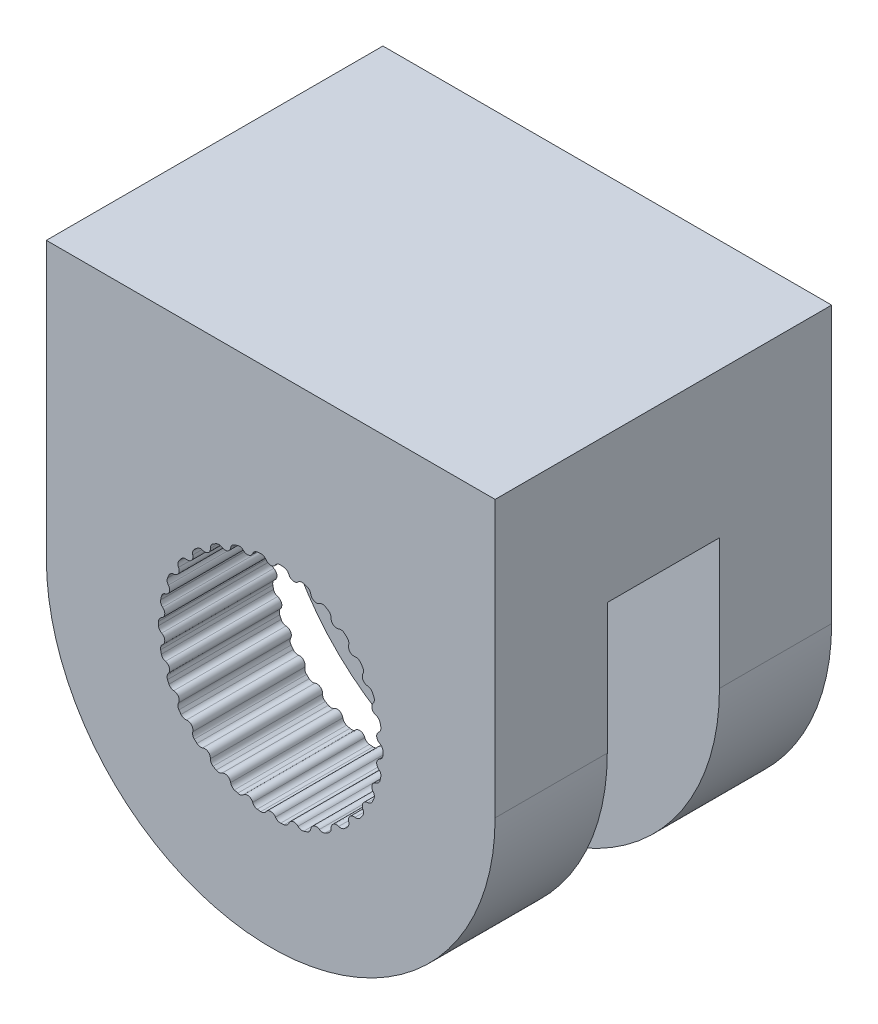
from build123d import *

# Parameters (mm, degrees)
BOSS_EXTRUDE1_DEPTH     = 10
BOSS_EXTRUDE2_DEPTH     = 20
CUT_EXTRUDE1_DEPTH      = 1
CUT_EXTRUDE1_DEPTH_BACK = 60
SKETCH4_R               = 20
CUT_EXTRUDE2_DEPTH      = 10


with BuildPart() as part:
    # Sketch1 → Boss-Extrude1 (new body)
    with BuildSketch(Plane.XY):
        with BuildLine():
            Line((-51.513982082, -77.637558877), (-11.513982082, -77.637558877))
            Line((-11.513982082, -77.637558877), (-11.513982082, -102.225983253))
            ThreePointArc((-11.513982082, -102.225983253), (-31.513982082, -122.225983253), (-51.513982082, -102.225983253))
            Line((-51.513982082, -102.225983253), (-51.513982082, -77.637558877))
        make_face()
        with BuildLine():
            ThreePointArc((-34.453140805, -111.784296179), (-34.604152026, -111.736548416), (-34.754388101, -111.686414999))
            ThreePointArc((-34.754388101, -111.686414999), (-34.976492372, -111.533468892), (-35.086858156, -111.28741562))
            ThreePointArc((-35.086858156, -111.28741562), (-35.377980191, -110.9046651), (-35.857217924, -110.944429354))
            ThreePointArc((-35.857217924, -110.944429354), (-36.113920264, -111.027053367), (-36.376198137, -110.964338649))
            ThreePointArc((-36.376198137, -110.964338649), (-36.513982082, -110.88623729), (-36.650511815, -110.805963573))
            ThreePointArc((-36.650511815, -110.805963573), (-36.835963291, -110.610181631), (-36.892759967, -110.346558877))
            ThreePointArc((-36.892759967, -110.346558877), (-37.097941979, -109.911644699), (-37.57497467, -109.850900881))
            ThreePointArc((-37.57497467, -109.850900881), (-37.843245946, -109.878347944), (-38.086753296, -109.762473057))
            ThreePointArc((-38.086753296, -109.762473057), (-38.205288146, -109.657431507), (-38.322144532, -109.550525836))
            ThreePointArc((-38.322144532, -109.550525836), (-38.462838094, -109.320464669), (-38.463583373, -109.050794011))
            ThreePointArc((-38.463583373, -109.050794011), (-38.573857924, -108.582724013), (-39.027836957, -108.42412692))
            ThreePointArc((-39.027836957, -108.42412692), (-39.295952427, -108.395197464), (-39.510046813, -108.231226696))
            ThreePointArc((-39.510046813, -108.231226696), (-39.604152026, -108.103835776), (-39.696227881, -107.974970441))
            ThreePointArc((-39.696227881, -107.974970441), (-39.786014545, -107.720684826), (-39.730675855, -107.456752167))
            ThreePointArc((-39.730675855, -107.456752167), (-39.741223418, -106.975983253), (-40.15230773, -106.726464338))
            ThreePointArc((-40.15230773, -106.726464338), (-40.408549462, -106.64242272), (-40.583873932, -106.43752238))
            ThreePointArc((-40.583873932, -106.43752238), (-40.649436658, -106.293349683), (-40.712707826, -106.148156718))
            ThreePointArc((-40.712707826, -106.148156718), (-40.747663483, -105.880760157), (-40.638659392, -105.634100621))
            ThreePointArc((-40.638659392, -105.634100621), (-40.549018987, -105.161644699), (-40.899242221, -104.832109137))
            ThreePointArc((-40.899242221, -104.832109137), (-41.132411221, -104.696628378), (-41.261303255, -104.459753596))
            ThreePointArc((-41.261303255, -104.459753596), (-41.295458089, -104.305100161), (-41.327159315, -104.149925195))
            ThreePointArc((-41.327159315, -104.149925195), (-41.305756236, -103.8811042), (-41.147850744, -103.662497992))
            ThreePointArc((-41.147850744, -103.662497992), (-40.961940088, -103.219003654), (-41.235995808, -102.82385373))
            ThreePointArc((-41.235995808, -102.82385373), (-41.435901473, -102.642854989), (-41.51272787, -102.384358328))
            ThreePointArc((-41.51272787, -102.384358328), (-41.513982082, -102.225983253), (-41.51272787, -102.067608177))
            ThreePointArc((-41.51272787, -102.067608177), (-41.435901473, -101.809111516), (-41.235995808, -101.628112775))
            ThreePointArc((-41.235995808, -101.628112775), (-40.961940088, -101.232962852), (-41.147850744, -100.789468514))
            ThreePointArc((-41.147850744, -100.789468514), (-41.305756236, -100.570862305), (-41.327159315, -100.30204131))
            ThreePointArc((-41.327159315, -100.30204131), (-41.295458089, -100.146866344), (-41.261303255, -99.992212909))
            ThreePointArc((-41.261303255, -99.992212909), (-41.132411221, -99.755338127), (-40.899242221, -99.619857368))
            ThreePointArc((-40.899242221, -99.619857368), (-40.549018987, -99.290321806), (-40.638659392, -98.817865884))
            ThreePointArc((-40.638659392, -98.817865884), (-40.747663483, -98.571206348), (-40.712707826, -98.303809787))
            ThreePointArc((-40.712707826, -98.303809787), (-40.649436658, -98.158616822), (-40.583873932, -98.014444125))
            ThreePointArc((-40.583873932, -98.014444125), (-40.408549462, -97.809543786), (-40.15230773, -97.725502167))
            ThreePointArc((-40.15230773, -97.725502167), (-39.741223418, -97.475983253), (-39.730675855, -96.995214338))
            ThreePointArc((-39.730675855, -96.995214338), (-39.786014545, -96.73128168), (-39.696227881, -96.476996065))
            ThreePointArc((-39.696227881, -96.476996065), (-39.604152026, -96.34813073), (-39.510046813, -96.220739809))
            ThreePointArc((-39.510046813, -96.220739809), (-39.295952427, -96.056769041), (-39.027836957, -96.027839585))
            ThreePointArc((-39.027836957, -96.027839585), (-38.573857924, -95.869242492), (-38.463583373, -95.401172494))
            ThreePointArc((-38.463583373, -95.401172494), (-38.462838094, -95.131501836), (-38.322144532, -94.901440669))
            ThreePointArc((-38.322144532, -94.901440669), (-38.205288146, -94.794534998), (-38.086753296, -94.689493448))
            ThreePointArc((-38.086753296, -94.689493448), (-37.843245946, -94.573618561), (-37.57497467, -94.601065624))
            ThreePointArc((-37.57497467, -94.601065624), (-37.097941979, -94.540321806), (-36.892759967, -94.105407628))
            ThreePointArc((-36.892759967, -94.105407628), (-36.835963291, -93.841784874), (-36.650511815, -93.646002932))
            ThreePointArc((-36.650511815, -93.646002932), (-36.513982082, -93.565729215), (-36.376198137, -93.487627856))
            ThreePointArc((-36.376198137, -93.487627856), (-36.113920264, -93.424913138), (-35.857217924, -93.507537151))
            ThreePointArc((-35.857217924, -93.507537151), (-35.377980191, -93.547301405), (-35.086858156, -93.164550885))
            ThreePointArc((-35.086858156, -93.164550885), (-34.976492372, -92.918497613), (-34.754388101, -92.765551506))
            ThreePointArc((-34.754388101, -92.765551506), (-34.604152026, -92.71541809), (-34.453140805, -92.667670326))
            ThreePointArc((-34.453140805, -92.667670326), (-34.183555209, -92.660856711), (-33.94964093, -92.795046609))
            ThreePointArc((-33.94964093, -92.795046609), (-33.489143145, -92.933581046), (-33.124804517, -92.619722217))
            ThreePointArc((-33.124804517, -92.619722217), (-32.965693138, -92.401992136), (-32.716643094, -92.298566343))
            ThreePointArc((-32.716643094, -92.298566343), (-32.559266715, -92.280764299), (-32.401628133, -92.265456937))
            ThreePointArc((-32.401628133, -92.265456937), (-32.136516999, -92.314842212), (-31.935613956, -92.494733253))
            ThreePointArc((-31.935613956, -92.494733253), (-31.513982082, -92.725983253), (-31.092350208, -92.494733253))
            ThreePointArc((-31.092350208, -92.494733253), (-30.891447165, -92.314842212), (-30.626336031, -92.265456937))
            ThreePointArc((-30.626336031, -92.265456937), (-30.468697449, -92.280764299), (-30.31132107, -92.298566343))
            ThreePointArc((-30.31132107, -92.298566343), (-30.062271026, -92.401992136), (-29.903159647, -92.619722217))
            ThreePointArc((-29.903159647, -92.619722217), (-29.538821019, -92.933581046), (-29.078323234, -92.795046609))
            ThreePointArc((-29.078323234, -92.795046609), (-28.844408955, -92.660856711), (-28.574823359, -92.667670326))
            ThreePointArc((-28.574823359, -92.667670326), (-28.423812138, -92.71541809), (-28.273576063, -92.765551506))
            ThreePointArc((-28.273576063, -92.765551506), (-28.051471792, -92.918497613), (-27.941106008, -93.164550885))
            ThreePointArc((-27.941106008, -93.164550885), (-27.649983973, -93.547301405), (-27.17074624, -93.507537151))
            ThreePointArc((-27.17074624, -93.507537151), (-26.9140439, -93.424913138), (-26.651766027, -93.487627856))
            ThreePointArc((-26.651766027, -93.487627856), (-26.513982082, -93.565729215), (-26.377452349, -93.646002932))
            ThreePointArc((-26.377452349, -93.646002932), (-26.192000873, -93.841784874), (-26.135204197, -94.105407628))
            ThreePointArc((-26.135204197, -94.105407628), (-25.930022185, -94.540321806), (-25.452989494, -94.601065624))
            ThreePointArc((-25.452989494, -94.601065624), (-25.184718218, -94.573618561), (-24.941210868, -94.689493448))
            ThreePointArc((-24.941210868, -94.689493448), (-24.822676018, -94.794534998), (-24.705819632, -94.901440669))
            ThreePointArc((-24.705819632, -94.901440669), (-24.56512607, -95.131501836), (-24.564380791, -95.401172494))
            ThreePointArc((-24.564380791, -95.401172494), (-24.45410624, -95.869242492), (-24.000127207, -96.027839585))
            ThreePointArc((-24.000127207, -96.027839585), (-23.732011737, -96.056769041), (-23.517917351, -96.220739809))
            ThreePointArc((-23.517917351, -96.220739809), (-23.423812138, -96.34813073), (-23.331736283, -96.476996065))
            ThreePointArc((-23.331736283, -96.476996065), (-23.241949619, -96.73128168), (-23.297288309, -96.995214338))
            ThreePointArc((-23.297288309, -96.995214338), (-23.286740746, -97.475983253), (-22.875656434, -97.725502167))
            ThreePointArc((-22.875656434, -97.725502167), (-22.619414702, -97.809543786), (-22.444090232, -98.014444125))
            ThreePointArc((-22.444090232, -98.014444125), (-22.378527506, -98.158616822), (-22.315256338, -98.303809787))
            ThreePointArc((-22.315256338, -98.303809787), (-22.280300681, -98.571206348), (-22.389304772, -98.817865884))
            ThreePointArc((-22.389304772, -98.817865884), (-22.478945177, -99.290321806), (-22.128721943, -99.619857368))
            ThreePointArc((-22.128721943, -99.619857368), (-21.895552943, -99.755338127), (-21.766660909, -99.992212909))
            ThreePointArc((-21.766660909, -99.992212909), (-21.732506075, -100.146866344), (-21.700804849, -100.30204131))
            ThreePointArc((-21.700804849, -100.30204131), (-21.722207928, -100.570862305), (-21.88011342, -100.789468514))
            ThreePointArc((-21.88011342, -100.789468514), (-22.066024076, -101.232962852), (-21.791968356, -101.628112775))
            ThreePointArc((-21.791968356, -101.628112775), (-21.592062691, -101.809111516), (-21.515236294, -102.067608177))
            ThreePointArc((-21.515236294, -102.067608177), (-21.513982082, -102.225983253), (-21.515236294, -102.384358328))
            ThreePointArc((-21.515236294, -102.384358328), (-21.592062691, -102.642854989), (-21.791968356, -102.82385373))
            ThreePointArc((-21.791968356, -102.82385373), (-22.066024076, -103.219003654), (-21.88011342, -103.662497992))
            ThreePointArc((-21.88011342, -103.662497992), (-21.722207928, -103.8811042), (-21.700804849, -104.149925195))
            ThreePointArc((-21.700804849, -104.149925195), (-21.732506075, -104.305100161), (-21.766660909, -104.459753596))
            ThreePointArc((-21.766660909, -104.459753596), (-21.895552943, -104.696628378), (-22.128721943, -104.832109137))
            ThreePointArc((-22.128721943, -104.832109137), (-22.478945177, -105.161644699), (-22.389304772, -105.634100621))
            ThreePointArc((-22.389304772, -105.634100621), (-22.280300681, -105.880760157), (-22.315256338, -106.148156718))
            ThreePointArc((-22.315256338, -106.148156718), (-22.378527506, -106.293349683), (-22.444090232, -106.43752238))
            ThreePointArc((-22.444090232, -106.43752238), (-22.619414702, -106.64242272), (-22.875656434, -106.726464338))
            ThreePointArc((-22.875656434, -106.726464338), (-23.286740746, -106.975983253), (-23.297288309, -107.456752167))
            ThreePointArc((-23.297288309, -107.456752167), (-23.241949619, -107.720684826), (-23.331736283, -107.974970441))
            ThreePointArc((-23.331736283, -107.974970441), (-23.423812138, -108.103835776), (-23.517917351, -108.231226696))
            ThreePointArc((-23.517917351, -108.231226696), (-23.732011737, -108.395197464), (-24.000127207, -108.42412692))
            ThreePointArc((-24.000127207, -108.42412692), (-24.45410624, -108.582724013), (-24.564380791, -109.050794011))
            ThreePointArc((-24.564380791, -109.050794011), (-24.56512607, -109.320464669), (-24.705819632, -109.550525836))
            ThreePointArc((-24.705819632, -109.550525836), (-24.822676018, -109.657431507), (-24.941210868, -109.762473057))
            ThreePointArc((-24.941210868, -109.762473057), (-25.184718218, -109.878347944), (-25.452989494, -109.850900881))
            ThreePointArc((-25.452989494, -109.850900881), (-25.930022185, -109.911644699), (-26.135204197, -110.346558877))
            ThreePointArc((-26.135204197, -110.346558877), (-26.192000873, -110.610181631), (-26.377452349, -110.805963573))
            ThreePointArc((-26.377452349, -110.805963573), (-26.513982082, -110.88623729), (-26.651766027, -110.964338649))
            ThreePointArc((-26.651766027, -110.964338649), (-26.9140439, -111.027053367), (-27.17074624, -110.944429354))
            ThreePointArc((-27.17074624, -110.944429354), (-27.649983973, -110.9046651), (-27.941106008, -111.28741562))
            ThreePointArc((-27.941106008, -111.28741562), (-28.051471792, -111.533468892), (-28.273576063, -111.686414999))
            ThreePointArc((-28.273576063, -111.686414999), (-28.423812138, -111.736548416), (-28.574823359, -111.784296179))
            ThreePointArc((-28.574823359, -111.784296179), (-28.844408955, -111.791109794), (-29.078323234, -111.656919896))
            ThreePointArc((-29.078323234, -111.656919896), (-29.538821019, -111.51838546), (-29.903159647, -111.832244288))
            ThreePointArc((-29.903159647, -111.832244288), (-30.062271026, -112.049974369), (-30.31132107, -112.153400162))
            ThreePointArc((-30.31132107, -112.153400162), (-30.468697449, -112.171202206), (-30.626336031, -112.186509568))
            ThreePointArc((-30.626336031, -112.186509568), (-30.891447165, -112.137124293), (-31.092350208, -111.957233253))
            ThreePointArc((-31.092350208, -111.957233253), (-31.513982082, -111.725983253), (-31.935613956, -111.957233253))
            ThreePointArc((-31.935613956, -111.957233253), (-32.136516999, -112.137124293), (-32.401628133, -112.186509568))
            ThreePointArc((-32.401628133, -112.186509568), (-32.559266715, -112.171202206), (-32.716643094, -112.153400162))
            ThreePointArc((-32.716643094, -112.153400162), (-32.965693138, -112.049974369), (-33.124804517, -111.832244288))
            ThreePointArc((-33.124804517, -111.832244288), (-33.489143145, -111.51838546), (-33.94964093, -111.656919896))
            ThreePointArc((-33.94964093, -111.656919896), (-34.183555209, -111.791109794), (-34.453140805, -111.784296179))
        make_face(mode=Mode.SUBTRACT)
    extrude(amount=BOSS_EXTRUDE1_DEPTH)

    # Sketch2 → Boss-Extrude2 (add)
    with BuildSketch(Plane(origin=(0, 0, 0), x_dir=(-1, 0, 0), z_dir=(0, 0, -1))):
        with BuildLine():
            Line((51.513982082, -102.225983253), (51.513982082, -77.637558877))
            Line((51.513982082, -77.637558877), (11.513982082, -77.637558877))
            Line((11.513982082, -77.637558877), (11.513982082, -102.225983253))
            ThreePointArc((11.513982082, -102.225983253), (31.513982082, -122.225983253), (51.513982082, -102.225983253))
        make_face()
    extrude(amount=BOSS_EXTRUDE2_DEPTH)

    # Sketch3 → Cut-Extrude1 (cut, two sides)
    with BuildSketch(Plane.ZY.offset(51.513982082)) as cut_extrude1_sk:
        Polygon((0, -92.298566343), (0, -90.600401808), (-10, -90.600401808), (-10, -122.225983253), (0, -122.225983253), align=None)
    extrude(amount=CUT_EXTRUDE1_DEPTH, mode=Mode.SUBTRACT)
    extrude(cut_extrude1_sk.sketch, amount=-CUT_EXTRUDE1_DEPTH_BACK, mode=Mode.SUBTRACT)

    # Sketch4 → Cut-Extrude2 (cut)
    with BuildSketch(Plane(origin=(0, 0, 0), x_dir=(-1, 0, 0), z_dir=(0, 0, -1))):
        with Locations((31.513982082, -102.225983253)):
            Circle(SKETCH4_R)
    extrude(amount=CUT_EXTRUDE2_DEPTH, mode=Mode.SUBTRACT)


solid = part.part
